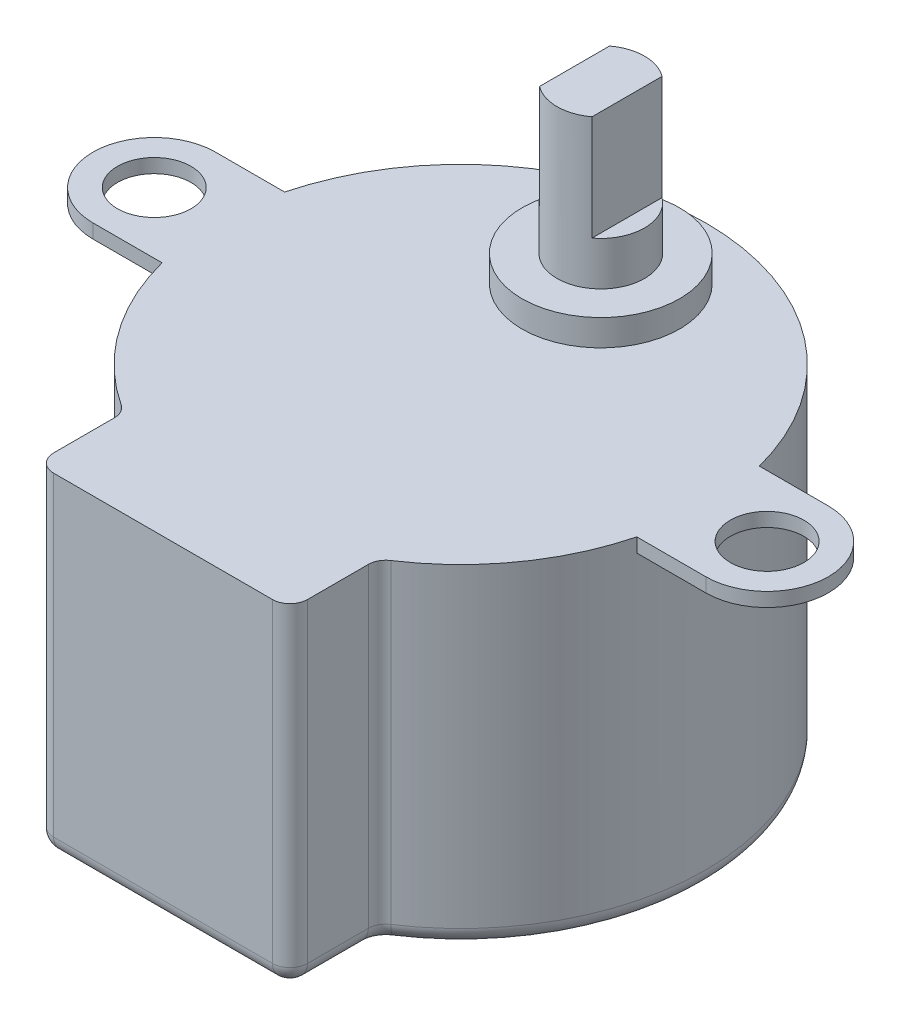
from build123d import *

# Parameters (mm, degrees)
SKETCH1_R           = 14
SKETCH1_W           = 14.5
SKETCH1_H           = 17
BOSS_EXTRUDE1_DEPTH = 19
SKETCH2_R           = 4.5
BOSS_EXTRUDE2_DEPTH = 1.5
SKETCH2_3_R         = 2.5
BOSS_EXTRUDE3_DEPTH = 10
CUT_EXTRUDE1_START  = -6
CUT_EXTRUDE1_DEPTH  = 6
FILLET1_R           = 1
SKETCH4_R           = 2.1
BOSS_EXTRUDE4_DEPTH = 0.8


with BuildPart() as part:
    # Sketch1 → Boss-Extrude1 (new body)
    with BuildSketch(Plane(origin=(0, 0, 0), x_dir=(1, 0, 0), z_dir=(0, 1, 0))):
        Circle(SKETCH1_R)
        with Locations((0, -8.5)):
            Rectangle(SKETCH1_W, SKETCH1_H)
    extrude(amount=BOSS_EXTRUDE1_DEPTH)

    # Sketch2 → Boss-Extrude2 (add)
    with BuildSketch(Plane(origin=(0, 19, 0), x_dir=(1, 0, 0), z_dir=(0, 1, 0))):
        with Locations((0, 8.000000036)):
            Circle(SKETCH2_R)
    extrude(amount=BOSS_EXTRUDE2_DEPTH)

    # Sketch2_3 → Boss-Extrude3 (add)
    with BuildSketch(Plane(origin=(0, 19, 0), x_dir=(1, 0, 0), z_dir=(0, 1, 0))):
        with Locations((0, 8.000000036)):
            Circle(SKETCH2_3_R)
    extrude(amount=BOSS_EXTRUDE3_DEPTH)

    # Sketch3 → Cut-Extrude1 (cut)
    with BuildSketch(Plane(origin=(0, 29, 0), x_dir=(1, 0, 0), z_dir=(0, 1, 0)).offset(CUT_EXTRUDE1_START)):
        with BuildLine():
            Line((-1.5, 6.000000036), (-1.5, 10.000000036))
            ThreePointArc((-1.5, 10.000000036), (-2.5, 8.000000036), (-1.5, 6.000000036))
        make_face()
        with BuildLine():
            ThreePointArc((1.5, 6.000000036), (2.5, 8.000000036), (1.5, 10.000000036))
            Line((1.5, 10.000000036), (1.5, 6.000000036))
        make_face()
    extrude(amount=CUT_EXTRUDE1_DEPTH, mode=Mode.SUBTRACT)

    # Fillet1
    fillet1_edges = [part.edges().sort_by_distance(p)[0] for p in [
        (-7.25, 0, 14.488269784),
        (0, 0, 17),
        (7.25, 0, 14.488269784),
        (0, 0, -14),
        (7.25, 9.5, 11.976539567),
        (-7.25, 9.5, 11.976539567),
        (-7.25, 9.5, 17),
        (7.25, 9.5, 17),
    ]]
    fillet(fillet1_edges, radius=FILLET1_R)

    # Sketch4 → Boss-Extrude4 (add)
    with BuildSketch(Plane(origin=(0, 19, 0), x_dir=(1, 0, 0), z_dir=(0, 1, 0))):
        with BuildLine():
            Line((-17.502332169, 3.500000036), (17.497667831, 3.500000036))
            ThreePointArc((17.497667831, 3.500000036), (20.997667831, 3.6e-08), (17.497667831, -3.499999964))
            Line((17.497667831, -3.499999964), (-17.502332169, -3.499999964))
            ThreePointArc((-17.502332169, -3.499999964), (-21.002332169, 3.6e-08), (-17.502332169, 3.500000036))
        make_face()
        with Locations((17.497667831, 3.6e-08)):
            Circle(SKETCH4_R, mode=Mode.SUBTRACT)
        with Locations((-17.502332169, 3.6e-08)):
            Circle(SKETCH4_R, mode=Mode.SUBTRACT)
    extrude(amount=-BOSS_EXTRUDE4_DEPTH)


solid = part.part
